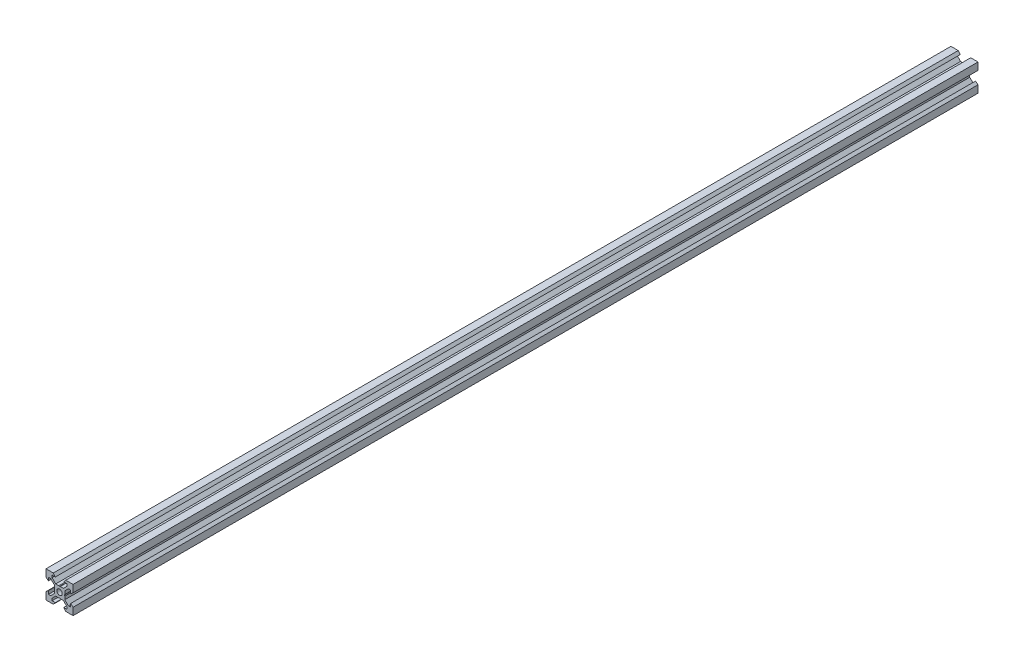
from build123d import *

# Parameters (mm, degrees)
SKETCH1_R           = 2
BOSS_EXTRUDE1_DEPTH = 334.19


with BuildPart() as part:
    # Sketch1 → Boss-Extrude1 (new body, symmetric)
    with BuildSketch(Plane.XY):
        Polygon((10, 10), (10, 4.610379336), (8.2, 3.1), (8.2, 5.5), (6.560660172, 5.5), (3.9, 2.839339828), (3.9, 0.519615242), (3.6, 0), (3.9, -0.519615242), (3.9, -2.839339828), (6.560660172, -5.5), (8.2, -5.5), (8.2, -3.1), (10, -4.610379336), (10, -10), (4.610379336, -10), (3.1, -8.2), (5.5, -8.2), (5.5, -6.560660172), (2.839339828, -3.9), (0.519615242, -3.9), (0, -3.6), (-0.519615242, -3.9), (-2.839339828, -3.9), (-5.5, -6.560660172), (-5.5, -8.2), (-3.1, -8.2), (-4.610379336, -10), (-10, -10), (-10, -4.610379336), (-8.2, -3.1), (-8.2, -5.5), (-6.560660172, -5.5), (-3.9, -2.839339828), (-3.9, -0.519615242), (-3.6, 0), (-3.9, 0.519615242), (-3.9, 2.839339828), (-6.560660172, 5.5), (-8.2, 5.5), (-8.2, 3.1), (-10, 4.610379336), (-10, 10), (-4.610379336, 10), (-3.1, 8.2), (-5.5, 8.2), (-5.5, 6.560660172), (-2.839339828, 3.9), (-0.519615242, 3.9), (0, 3.6), (0.519615242, 3.9), (2.839339828, 3.9), (5.5, 6.560660172), (5.5, 8.2), (3.1, 8.2), (4.610379336, 10), align=None)
        Circle(SKETCH1_R, mode=Mode.SUBTRACT)
    extrude(amount=BOSS_EXTRUDE1_DEPTH, both=True)


solid = part.part
